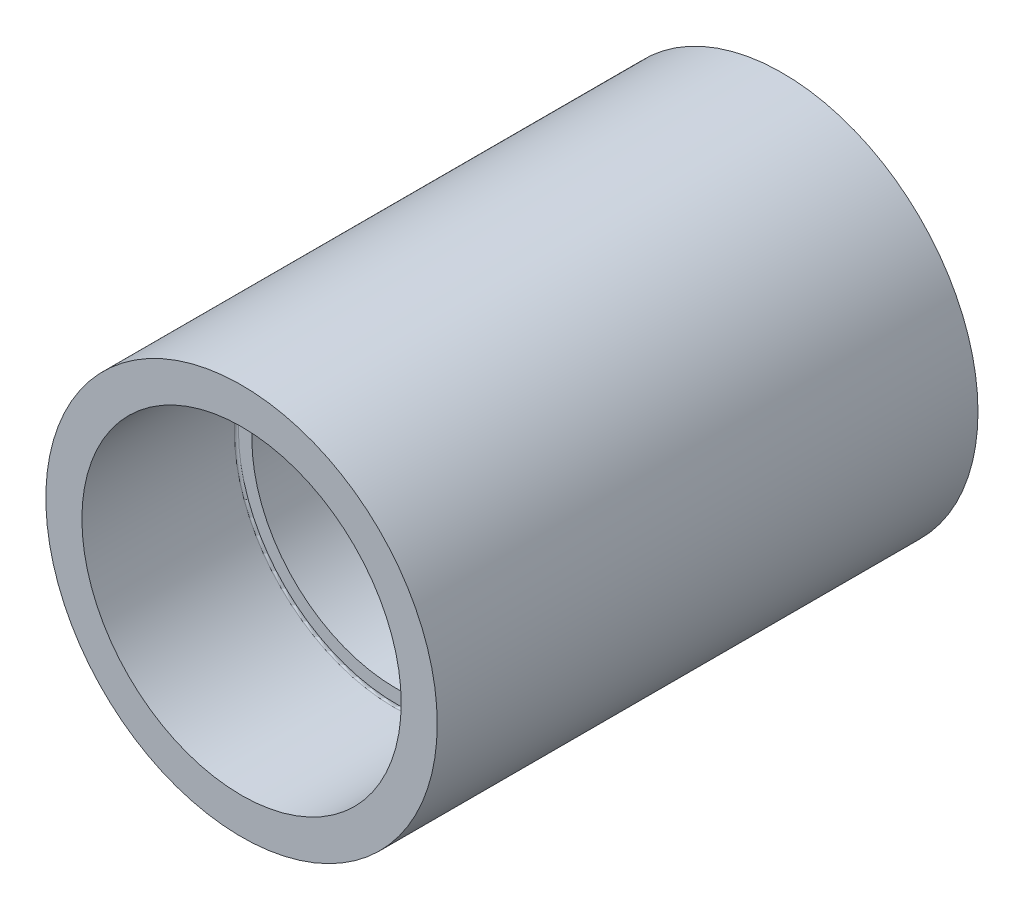
from build123d import *

# Parameters (mm, degrees)
CONG_1_R = 0.4


with BuildPart() as part:
    # Esquisse1 → Révolution1 (revolve)
    with BuildSketch(Plane(origin=(0, 0, 0), x_dir=(0, 0, -1), z_dir=(1, 0, 0)), mode=Mode.PRIVATE) as r_volution1_sk:
        Polygon((-52.5, 38), (52.5, 38), (52.5, 31), (22.5, 31), (22.5, 28), (-22.5, 28), (-22.5, 31), (-52.5, 31), align=None)
    revolve(r_volution1_sk.sketch.rotate(Axis((0, 0, 52.5), (0, 0, -1)), 90), axis=Axis((0, 0, 52.5), (0, 0, -1)))  # turned: the seam where the file's is

    # Congé1
    cong_1_edges = [part.edges().sort_by_distance(p)[0] for p in [
        (-31, 0, 22.5),
        (-31, 0, -22.5),
    ]]
    fillet(cong_1_edges, radius=CONG_1_R)


solid = part.part
